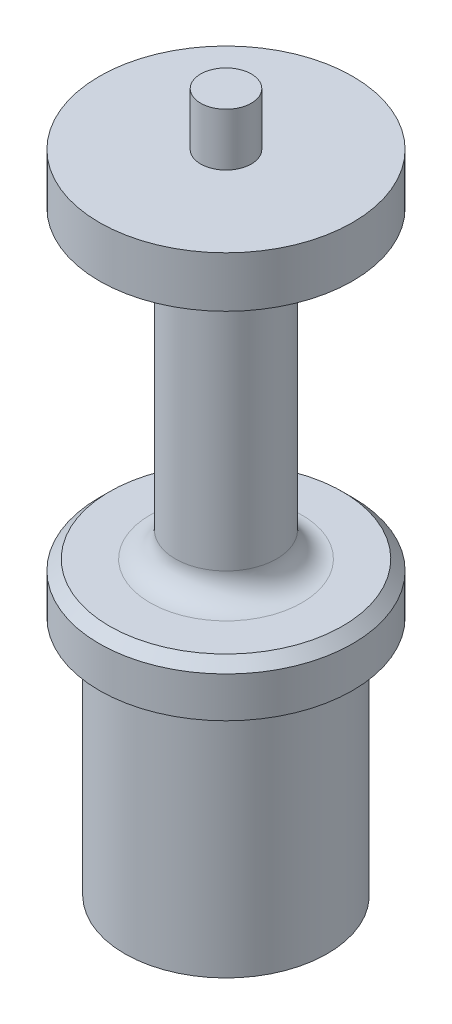
from build123d import *

# Parameters (mm, degrees)
SKETCH1_R           = 12.7
BOSS_EXTRUDE1_DEPTH = 30.1625
SKETCH4_R           = 15.875
BOSS_EXTRUDE2_DEPTH = 50.8
CUT_EXTRUDE1_DEPTH  = 11.176
SKETCH3_R           = 6
CUT_EXTRUDE2_DEPTH  = 8
SKETCH5_R           = 3.175
BOSS_EXTRUDE3_DEPTH = 6.604
CUT_EXTRUDE3_START  = -6.35
SKETCH9_R           = 15.875
SKETCH9_R_2         = 6.35
CUT_EXTRUDE3_DEPTH  = 38.1
FILLET1_R           = 3.175
CHAMFER1_SIZE       = 1.27


with BuildPart() as part:
    # Sketch1 → Boss-Extrude1 (new body)
    with BuildSketch(Plane(origin=(0, 0, 0), x_dir=(1, 0, 0), z_dir=(0, 1, 0))):
        Circle(SKETCH1_R)
    extrude(amount=BOSS_EXTRUDE1_DEPTH)

    # Sketch4 → Boss-Extrude2 (add)
    with BuildSketch(Plane(origin=(0, 30.1625, 0), x_dir=(1, 0, 0), z_dir=(0, 1, 0))):
        Circle(SKETCH4_R)
    extrude(amount=BOSS_EXTRUDE2_DEPTH)

    # Sketch2 → Cut-Extrude1 (cut)
    with BuildSketch(Plane.XZ):
        with BuildLine():
            Line((-7, 2.899494937), (-8.776962921, 1.122532015))
            ThreePointArc((-8.776962921, 1.122532015), (-9.241930906, 0), (-8.776962921, -1.122532015))
            Line((-8.776962921, -1.122532015), (-7, -2.899494937))
            Line((-7, -2.899494937), (-7, 2.899494937))
        make_face()
        Polygon((-2.899494937, 7), (-7, 2.899494937), (-7, -2.899494937), (-2.899494937, -7), (2.899494937, -7), (7, -2.899494937), (7, 2.899494937), (2.899494937, 7), align=None)
        with BuildLine():
            Line((-7, 5.4125), (-7, 2.899494937))
            Line((-7, 2.899494937), (-2.899494937, 7))
            Line((-2.899494937, 7), (-5.4125, 7))
            ThreePointArc((-5.4125, 7), (-6.535032015, 6.535032015), (-7, 5.4125))
        make_face()
        with BuildLine():
            Line((-1.122532015, 8.776962921), (-2.899494937, 7))
            Line((-2.899494937, 7), (2.899494937, 7))
            Line((2.899494937, 7), (1.122532015, 8.776962921))
            ThreePointArc((1.122532015, 8.776962921), (0, 9.241930906), (-1.122532015, 8.776962921))
        make_face()
        with BuildLine():
            Line((5.4125, 7), (2.899494937, 7))
            Line((2.899494937, 7), (7, 2.899494937))
            Line((7, 2.899494937), (7, 5.4125))
            ThreePointArc((7, 5.4125), (6.535032015, 6.535032015), (5.4125, 7))
        make_face()
        with BuildLine():
            Line((8.776962921, 1.122532015), (7, 2.899494937))
            Line((7, 2.899494937), (7, -2.899494937))
            Line((7, -2.899494937), (8.776962921, -1.122532015))
            ThreePointArc((8.776962921, -1.122532015), (9.241930906, 0), (8.776962921, 1.122532015))
        make_face()
        with BuildLine():
            Line((7, -2.899494937), (2.899494937, -7))
            Line((2.899494937, -7), (5.4125, -7))
            ThreePointArc((5.4125, -7), (6.535032015, -6.535032015), (7, -5.4125))
            Line((7, -5.4125), (7, -2.899494937))
        make_face()
        with BuildLine():
            Line((2.899494937, -7), (-2.899494937, -7))
            Line((-2.899494937, -7), (-1.122532015, -8.776962921))
            ThreePointArc((-1.122532015, -8.776962921), (0, -9.241930906), (1.122532015, -8.776962921))
            Line((1.122532015, -8.776962921), (2.899494937, -7))
        make_face()
        with BuildLine():
            Line((-2.899494937, -7), (-7, -2.899494937))
            Line((-7, -2.899494937), (-7, -5.4125))
            ThreePointArc((-7, -5.4125), (-6.535032015, -6.535032015), (-5.4125, -7))
            Line((-5.4125, -7), (-2.899494937, -7))
        make_face()
    extrude(amount=-CUT_EXTRUDE1_DEPTH, mode=Mode.SUBTRACT)

    # Sketch3 → Cut-Extrude2 (cut)
    with BuildSketch(Plane.XZ.offset(-11.176)):
        Circle(SKETCH3_R)
    extrude(amount=-CUT_EXTRUDE2_DEPTH, mode=Mode.SUBTRACT)

    # Sketch5 → Boss-Extrude3 (add)
    with BuildSketch(Plane(origin=(0, 80.9625, 0), x_dir=(1, 0, 0), z_dir=(0, 1, 0))):
        Circle(SKETCH5_R)
    extrude(amount=BOSS_EXTRUDE3_DEPTH)

    # Sketch9 → Cut-Extrude3 (cut)
    with BuildSketch(Plane(origin=(0, 80.9625, 0), x_dir=(1, 0, 0), z_dir=(0, 1, 0)).offset(CUT_EXTRUDE3_START)):
        Circle(SKETCH9_R)
        Circle(SKETCH9_R_2, mode=Mode.SUBTRACT)
    extrude(amount=-CUT_EXTRUDE3_DEPTH, mode=Mode.SUBTRACT)

    # Fillet1
    fillet1_edges = [part.edges().sort_by_distance(p)[0] for p in [
        (-6.35, 36.5125, 0),
        (-6.35, 74.6125, 0),
    ]]
    fillet(fillet1_edges, radius=FILLET1_R)

    # Chamfer1
    chamfer1_edges = [part.edges().sort_by_distance(p)[0] for p in [
        (-15.875, 36.5125, 0),
    ]]
    chamfer(chamfer1_edges, length=CHAMFER1_SIZE)


solid = part.part
